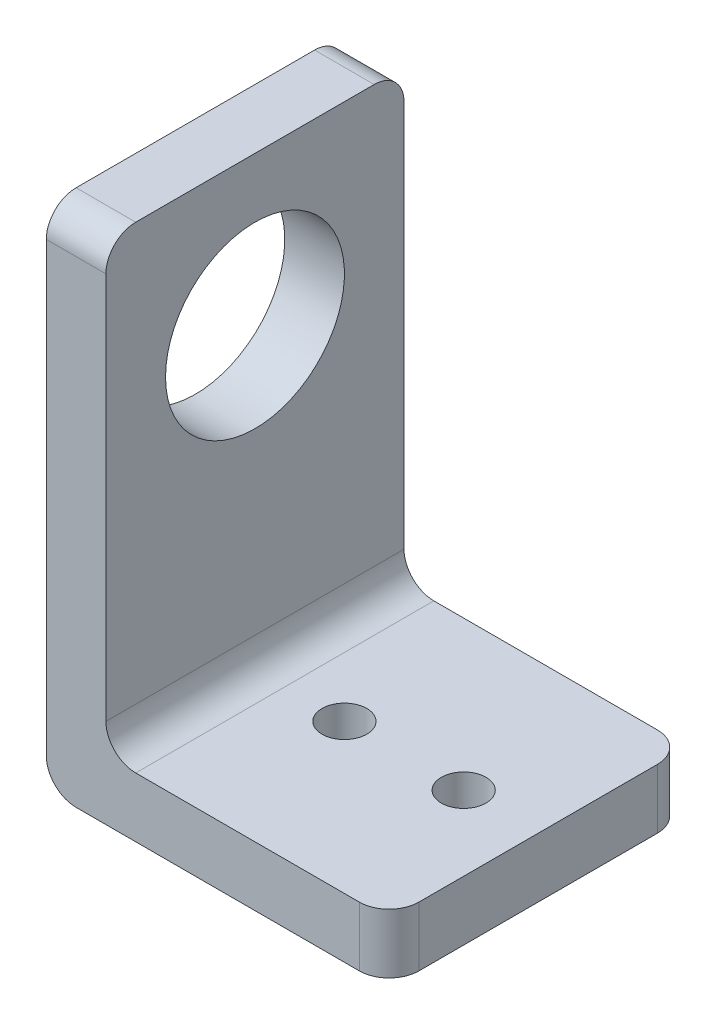
from build123d import *

# Parameters (mm, degrees)
BOSS_EXTRUDE1_DEPTH = 20
SKETCH2_R           = 6
CUT_EXTRUDE1_DEPTH  = 4
SKETCH3_R           = 1.5
CUT_EXTRUDE2_DEPTH  = 4
FILLET1_R           = 2


with BuildPart() as part:
    # Sketch1 → Boss-Extrude1 (new body)
    with BuildSketch(Plane.XY):
        Polygon((0, 0), (23, 0), (23, 4), (4, 4), (4, 34), (0, 34), align=None)
    extrude(amount=BOSS_EXTRUDE1_DEPTH)

    # Sketch2 → Cut-Extrude1 (cut)
    with BuildSketch(Plane.ZY):
        with Locations((10, 24)):
            Circle(SKETCH2_R)
    extrude(amount=-CUT_EXTRUDE1_DEPTH, mode=Mode.SUBTRACT)

    # Sketch3 → Cut-Extrude2 (cut)
    with BuildSketch(Plane(origin=(0, 4, 0), x_dir=(1, 0, 0), z_dir=(0, 1, 0))):
        with Locations((18, -10)):
            Circle(SKETCH3_R)
        with Locations((10, -10)):
            Circle(SKETCH3_R)
    extrude(amount=-CUT_EXTRUDE2_DEPTH, mode=Mode.SUBTRACT)

    # Fillet1
    fillet1_edges = [part.edges().sort_by_distance(p)[0] for p in [
        (23, 2, 20),
        (4, 4, 10),
        (0, 0, 10),
        (2, 34, 20),
        (2, 34, 0),
        (23, 2, 0),
    ]]
    fillet(fillet1_edges, radius=FILLET1_R)


solid = part.part
